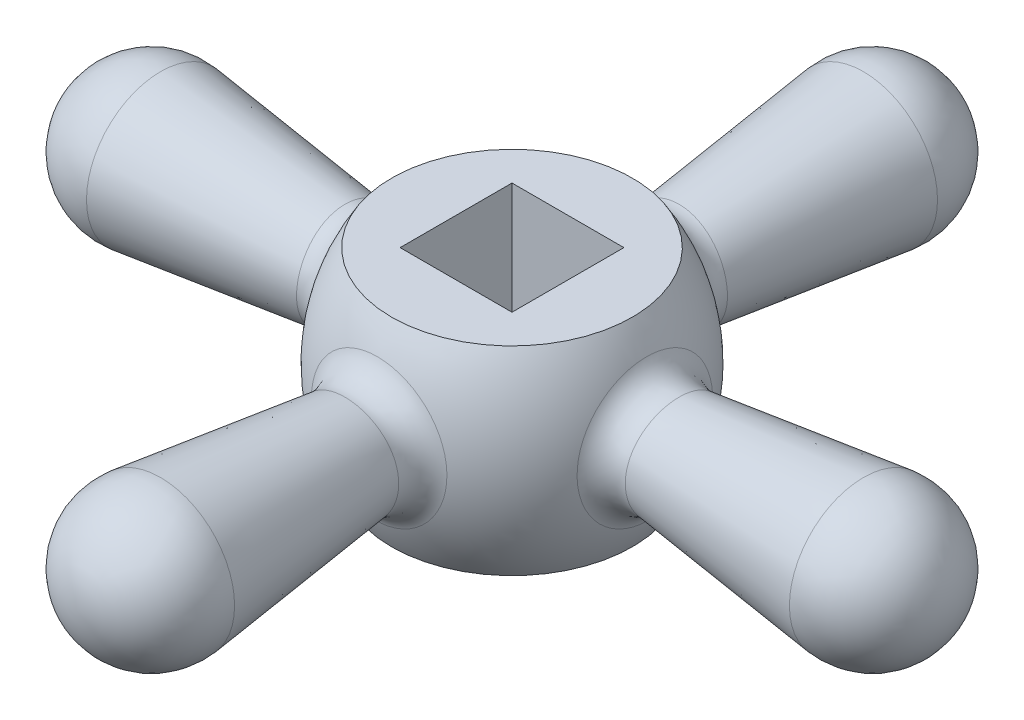
from build123d import *

# Parameters (mm, degrees)
FILLET1_R                = 2.5
CIRPATTERN3_COUNT        = 4
FILLET1_OF_CIRPATTERN3_R = 2.5
SKETCH3_W                = 9
SKETCH3_H                = 9
CUT_EXTRUDE1_DEPTH       = 11


with BuildPart() as part:
    # Sketch1 → Revolve1 (revolve)
    with BuildSketch(Plane.XY, mode=Mode.PRIVATE) as revolve1_sk:
        with BuildLine():
            Line((0, 7.830238727), (0, -8.169761273))
            Line((0, -8.169761273), (-9.68857754, -8.169761273))
            ThreePointArc((-9.68857754, -8.169761273), (-12, -0.169761273), (-9.68857754, 7.830238727))
            Line((-9.68857754, 7.830238727), (0, 7.830238727))
        make_face()
    revolve(revolve1_sk.sketch.rotate(Axis((0, 7.830238727, 0), (0, -1, 0)), 270), axis=Axis((0, 7.830238727, 0), (0, -1, 0)))

    # Sketch2 → Revolve2 (revolve)
    with BuildSketch(Plane.XY):
        with BuildLine():
            Line((0, 0), (-35, 0))
            ThreePointArc((-35, 0), (-32.975720289, -4.493734325), (-28.26878394, -5.95527691))
            Line((-28.26878394, -5.95527691), (0, -2.484306687))
            Line((0, -2.484306687), (0, 0))
        make_face()
    revolve2 = revolve(axis=Axis((0, 0, 0), (-1, 0, 0)))

    # Fillet1
    fillet1_edges = [part.edges().sort_by_distance(p)[0] for p in [
        (-11.440440634, 3.889016163, 1e-09),
    ]]
    fillet(fillet1_edges, radius=FILLET1_R)

    # CirPattern3: Revolve2 ×4 about axis
    cirpattern3_axis = Axis((0, 7.830238727, 0), (0, 1, 0))
    for i in range(1, CIRPATTERN3_COUNT):
        add(revolve2.rotate(cirpattern3_axis, i * 360 / CIRPATTERN3_COUNT))

    # Fillet1 of CirPattern3
    fillet1_of_cirpattern3_edges = [part.edges().sort_by_distance(p)[0] for p in [
        (1e-09, 3.889016163, 11.440440634),
        (11.440440634, 3.889016163, -1e-09),
        (-1e-09, 3.889016163, -11.440440634),
    ]]
    fillet(fillet1_of_cirpattern3_edges, radius=FILLET1_OF_CIRPATTERN3_R)

    # Sketch3 → Cut-Extrude1 (cut)
    with BuildSketch(Plane(origin=(0, 7.830238727, 0), x_dir=(1, 0, 0), z_dir=(0, 1, 0))):
        Rectangle(SKETCH3_W, SKETCH3_H)
    extrude(amount=-CUT_EXTRUDE1_DEPTH, mode=Mode.SUBTRACT)


solid = part.part
